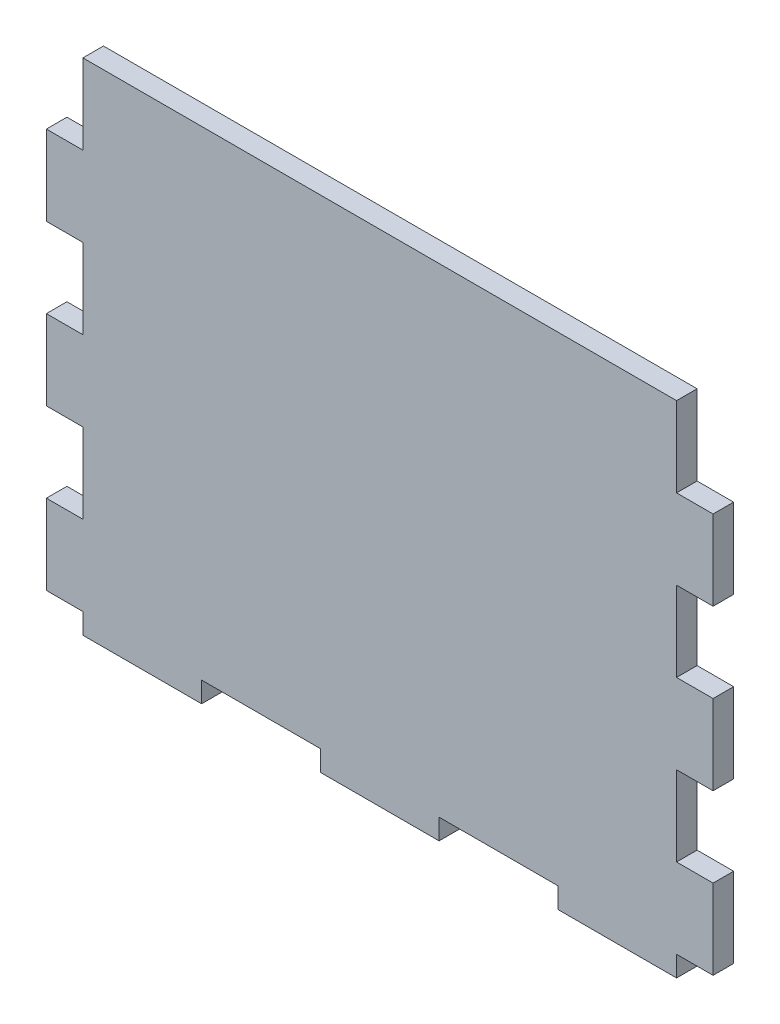
from build123d import *

# Parameters (mm, degrees)
SKETCH1_W           = 65
SKETCH1_H           = 70
BOSS_EXTRUDE1_DEPTH = 2.25
SKETCH2_W           = 4
SKETCH2_H           = 8.75
SKETCH2_W_2         = 13
SKETCH2_H_2         = 2.25
BOSS_EXTRUDE2_DEPTH = 2.25
SKETCH3_W           = 73
SKETCH3_H           = 17.5
CUT_EXTRUDE1_DEPTH  = 3.25


with BuildPart() as part:
    # Sketch1 → Boss-Extrude1 (new body)
    with BuildSketch(Plane.XY):
        with Locations((32.5, 35)):
            Rectangle(SKETCH1_W, SKETCH1_H)
    extrude(amount=BOSS_EXTRUDE1_DEPTH)

    # Sketch2 → Boss-Extrude2 (add)
    with BuildSketch(Plane.XY.offset(2.25)):
        with Locations((67, 39.375)):
            Rectangle(SKETCH2_W, SKETCH2_H)
        with Locations((67, 21.875)):
            Rectangle(SKETCH2_W, SKETCH2_H)
        with Locations((67, 4.375)):
            Rectangle(SKETCH2_W, SKETCH2_H)
        with Locations((6.5, -1.125)):
            Rectangle(SKETCH2_W_2, SKETCH2_H_2)
        with Locations((-2, 4.375)):
            Rectangle(SKETCH2_W, SKETCH2_H)
        with Locations((-2, 21.875)):
            Rectangle(SKETCH2_W, SKETCH2_H)
        with Locations((-2, 56.875)):
            Rectangle(SKETCH2_W, SKETCH2_H)
        with Locations((67, 56.875)):
            Rectangle(SKETCH2_W, SKETCH2_H)
        with Locations((58.5, -1.125)):
            Rectangle(SKETCH2_W_2, SKETCH2_H_2)
        with Locations((32.5, -1.125)):
            Rectangle(SKETCH2_W_2, SKETCH2_H_2)
        with Locations((-2, 39.375)):
            Rectangle(SKETCH2_W, SKETCH2_H)
    extrude(amount=-BOSS_EXTRUDE2_DEPTH)

    # Sketch3 → Cut-Extrude1 (cut, through all)
    with BuildSketch(Plane(origin=(0, 0, 0), x_dir=(-1, 0, 0), z_dir=(0, 0, -1))):
        with Locations((-32.5, 61.25)):
            Rectangle(SKETCH3_W, SKETCH3_H)
    extrude(amount=-CUT_EXTRUDE1_DEPTH, mode=Mode.SUBTRACT)


solid = part.part
